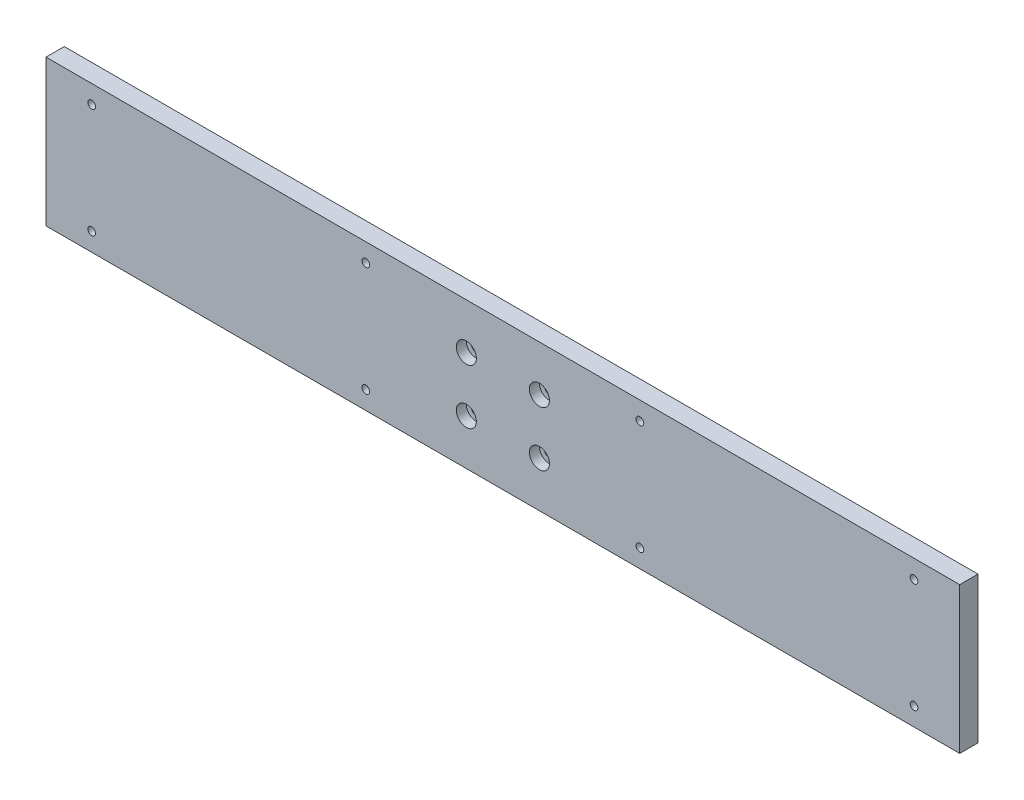
from build123d import *

# Parameters (mm, degrees)
SKETCH1_W             = 500
SKETCH1_H             = 80
BOSS_EXTRUDE1_DEPTH   = 10
SKETCH2_R             = 2.75
CUT_EXTRUDE1_DEPTH    = 11
SKETCH3_R             = 5.5
CUT_EXTRUDE2_DEPTH    = 5.5
M5_TAPPED_HOLE1_D     = 4.2
M5_TAPPED_HOLE1_DEPTH = 12.4
M5_TAPPED_HOLE1_TIP   = 1.2618073


with BuildPart() as part:
    # Sketch1 → Boss-Extrude1 (new body)
    with BuildSketch(Plane.XY):
        Rectangle(SKETCH1_W, SKETCH1_H)
    extrude(amount=BOSS_EXTRUDE1_DEPTH)

    # Sketch2 → Cut-Extrude1 (cut, through all)
    with BuildSketch(Plane.XY.offset(10)):
        with Locations((-20, 15)):
            Circle(SKETCH2_R)
        with Locations((20, 15)):
            Circle(SKETCH2_R)
        with Locations((20, -15)):
            Circle(SKETCH2_R)
        with Locations((-20, -15)):
            Circle(SKETCH2_R)
    extrude(amount=-CUT_EXTRUDE1_DEPTH, mode=Mode.SUBTRACT)

    # Sketch3 → Cut-Extrude2 (cut)
    with BuildSketch(Plane.XY.offset(10)):
        with Locations((20, 15)):
            Circle(SKETCH3_R)
        with Locations((20, -15)):
            Circle(SKETCH3_R)
        with Locations((-20, -15)):
            Circle(SKETCH3_R)
        with Locations((-20, 15)):
            Circle(SKETCH3_R)
    extrude(amount=-CUT_EXTRUDE2_DEPTH, mode=Mode.SUBTRACT)

    # M5 Tapped Hole1
    with Locations(Plane.XY.offset(10)):
        with Locations((-225, 30), (-225, -30), (-75, -30), (-75, 30), (75, 30), (75, -30), (225, -30), (225, 30)):
            Hole(M5_TAPPED_HOLE1_D / 2, depth=M5_TAPPED_HOLE1_DEPTH)
            with Locations((0, 0, -(M5_TAPPED_HOLE1_DEPTH + M5_TAPPED_HOLE1_TIP / 2))):  # 118° drill point
                Cone(0, M5_TAPPED_HOLE1_D / 2, M5_TAPPED_HOLE1_TIP, mode=Mode.SUBTRACT)


solid = part.part
